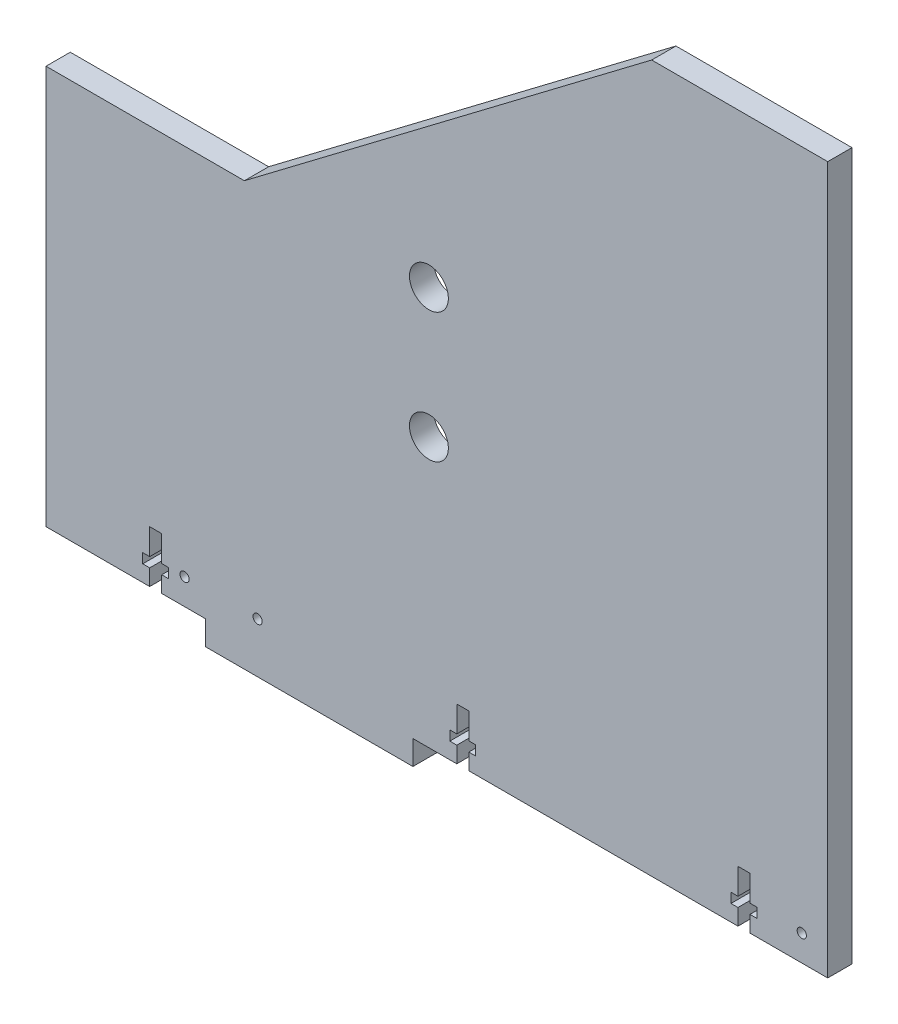
from build123d import *

# Parameters (mm, degrees)
BOSS_EXTRUDE1_DEPTH = 5.9436
SKETCH3_R           = 4.7625
CUT_EXTRUDE1_DEPTH  = 6.9436
CUT_EXTRUDE2_DEPTH  = 6.9436
SKETCH5_W           = 50.8
SKETCH5_H           = 5.9436
BOSS_EXTRUDE2_DEPTH = 5.9436
SKETCH6_R           = 4.7625
CUT_EXTRUDE3_DEPTH  = 6.9436
SKETCH7_W           = 12.7
SKETCH7_H           = 97.7138
BOSS_EXTRUDE3_DEPTH = 5.9436
SKETCH8_R           = 1.1303
CUT_EXTRUDE4_DEPTH  = 6.9436


with BuildPart() as part:
    # Sketch1 → Boss-Extrude1 (new body)
    with BuildSketch(Plane.XY):
        Polygon((0, 0), (0, 97.7138), (35.9029, 97.7138), (135.6995, 173.228), (178.8287, 173.228), (178.8287, 0), align=None)
    extrude(amount=BOSS_EXTRUDE1_DEPTH)

    # Sketch3 → Cut-Extrude1 (cut, through all)
    with BuildSketch(Plane.XY.offset(5.9436)):
        with Locations((81.1149, 97.7138)):
            Circle(SKETCH3_R)
    extrude(amount=-CUT_EXTRUDE1_DEPTH, mode=Mode.SUBTRACT)

    # Sketch4 → Cut-Extrude2 (cut, through all)
    with BuildSketch(Plane.XY.offset(5.9436)):
        Polygon((12.7, 3.96875), (12.7, 0), (15.6464, 0), (15.6464, 3.96875), (17.3482, 3.96875), (17.3482, 6.35), (15.6464, 6.35), (15.6464, 12.7), (12.7, 12.7), (12.7, 6.35), (10.9982, 6.35), (10.9982, 3.96875), align=None)
        Polygon((87.94115, 3.96875), (87.94115, 0), (90.88755, 0), (90.88755, 3.96875), (92.58935, 3.96875), (92.58935, 6.35), (90.88755, 6.35), (90.88755, 12.7), (87.94115, 12.7), (87.94115, 6.35), (86.23935, 6.35), (86.23935, 3.96875), align=None)
        Polygon((156.8323, 3.96875), (156.8323, 0), (159.7787, 0), (159.7787, 3.96875), (161.4805, 3.96875), (161.4805, 6.35), (159.7787, 6.35), (159.7787, 12.7), (156.8323, 12.7), (156.8323, 6.35), (155.1305, 6.35), (155.1305, 3.96875), align=None)
    extrude(amount=-CUT_EXTRUDE2_DEPTH, mode=Mode.SUBTRACT)

    # Sketch5 → Boss-Extrude2 (add)
    with BuildSketch(Plane.XY.offset(5.9436)):
        with Locations((51.793775, -2.9718)):
            Rectangle(SKETCH5_W, SKETCH5_H)
    extrude(amount=-BOSS_EXTRUDE2_DEPTH)

    # Sketch6 → Cut-Extrude3 (cut, through all)
    with BuildSketch(Plane.XY.offset(5.9436)):
        with Locations((81.1149, 65.9638)):
            Circle(SKETCH6_R)
    extrude(amount=-CUT_EXTRUDE3_DEPTH, mode=Mode.SUBTRACT)

    # Sketch7 → Boss-Extrude3 (add)
    with BuildSketch(Plane.XY.offset(5.9436)):
        with Locations((-6.35, 48.8569)):
            Rectangle(SKETCH7_W, SKETCH7_H)
    extrude(amount=-BOSS_EXTRUDE3_DEPTH)

    # Sketch8 → Cut-Extrude4 (cut, through all)
    with BuildSketch(Plane.XY.offset(5.9436)):
        with Locations((39.1414, 6.35)):
            Circle(SKETCH8_R)
        with Locations((172.4787, 6.35)):
            Circle(SKETCH8_R)
        with Locations((21.2344, 6.35)):
            Circle(SKETCH8_R)
    extrude(amount=-CUT_EXTRUDE4_DEPTH, mode=Mode.SUBTRACT)


solid = part.part
